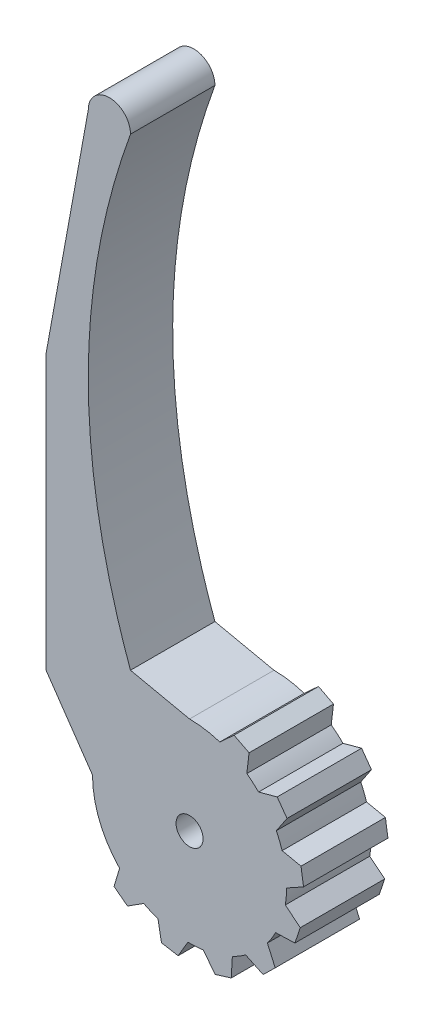
from build123d import *

# Parameters (mm, degrees)
EXTRUDE_2_DEPTH     = 10
SKETCH_2_R          = 1.6
CUT_EXTRUDE_1_DEPTH = 10


with BuildPart() as part:
    # 草圖1 → 填料-伸長2 (new body)
    with BuildSketch(Plane.XY):
        with BuildLine():
            ThreePointArc((0, 55), (-2.5, 57.5), (-5, 55))
            Line((-5, 55), (-10, 27.5))
            Line((-10, 27.5), (-10, -5))
            Line((-10, -5), (-4.5, -13))
            ThreePointArc((-4.5, -13), (-3.667869554, -17.294945772), (-1.291902751, -20.968334127))
            Line((-1.291902751, -20.968334127), (-1.947985517, -23.157930655))
            Line((-1.947985517, -23.157930655), (-0.353660285, -24.365459974))
            Line((-0.353660285, -24.365459974), (1.576282518, -23.140674962))
            ThreePointArc((1.576282518, -23.140674962), (2.401767343, -23.540695254), (3.256508451, -23.873650308))
            Line((3.256508451, -23.873650308), (3.671596164, -26.12142248))
            Line((3.671596164, -26.12142248), (5.641228986, -26.468620617))
            Line((5.641228986, -26.468620617), (6.799870704, -24.498258488))
            ThreePointArc((6.799870704, -24.498258488), (7.716939899, -24.477630295), (8.629447558, -24.383975608))
            Line((8.629447558, -24.383975608), (10.024280034, -26.194837259))
            Line((10.024280034, -26.194837259), (11.935396246, -25.605231608))
            Line((11.935396246, -25.605231608), (12.067538645, -23.323277197))
            ThreePointArc((12.067538645, -23.323277197), (12.874201866, -22.886544009), (13.643490442, -22.386907624))
            Line((13.643490442, -22.386907624), (15.710846923, -23.362004916))
            Line((15.710846923, -23.362004916), (17.142510983, -21.965459886))
            Line((17.142510983, -21.965459886), (16.219048856, -19.874528216))
            ThreePointArc((16.219048856, -19.874528216), (16.737633381, -19.117883305), (17.194262154, -18.322313325))
            Line((17.194262154, -18.322313325), (19.478794182, -18.246874857))
            Line((19.478794182, -18.246874857), (20.115672942, -16.350988403))
            Line((20.115672942, -16.350988403), (18.340004717, -14.911620519))
            ThreePointArc((18.340004717, -14.911620519), (18.456288995, -14.001719757), (18.499682563, -13.085445547))
            Line((18.499682563, -13.085445547), (20.498207378, -11.976087123))
            Line((20.498207378, -11.976087123), (20.200024227, -9.998440337))
            Line((20.200024227, -9.998440337), (17.963252163, -9.527666203))
            ThreePointArc((17.963252163, -9.527666203), (17.651623839, -8.664921039), (17.272224493, -7.829757842))
            Line((17.272224493, -7.829757842), (18.544554248, -5.930822735))
            Line((18.544554248, -5.930822735), (17.376985928, -4.307004944))
            Line((17.376985928, -4.307004944), (15.171773349, -4.908515567))
            ThreePointArc((15.171773349, -4.908515567), (14.50087055, -4.28295113), (13.782243416, -3.712848971))
            Line((13.782243416, -3.712848971), (14.048139364, -1.442589758))
            Line((14.048139364, -1.442589758), (12.268350249, -0.530257194))
            Line((12.268350249, -0.530257194), (10.580409299, -2.07156602))
            ThreePointArc((10.580409299, -2.07156602), (8.812871925, -1.643790448), (7, -1.5))
            Line((7, -1.5), (0, 0))
            add(Edge.make_bspline(
                [(0, 55), (-10, 27.5), (0, 0)],
                knots=[0, 0, 0, 1, 1, 1], degree=2))
        make_face()
    extrude(amount=EXTRUDE_2_DEPTH)

    # 草圖2 → 除料-伸長1 (cut)
    with BuildSketch(Plane(origin=(0, 0, 0), x_dir=(-1, 0, 0), z_dir=(0, 0, -1))):
        with Locations((-7, -13)):
            Circle(SKETCH_2_R)
    extrude(amount=-CUT_EXTRUDE_1_DEPTH, mode=Mode.SUBTRACT)


solid = part.part
